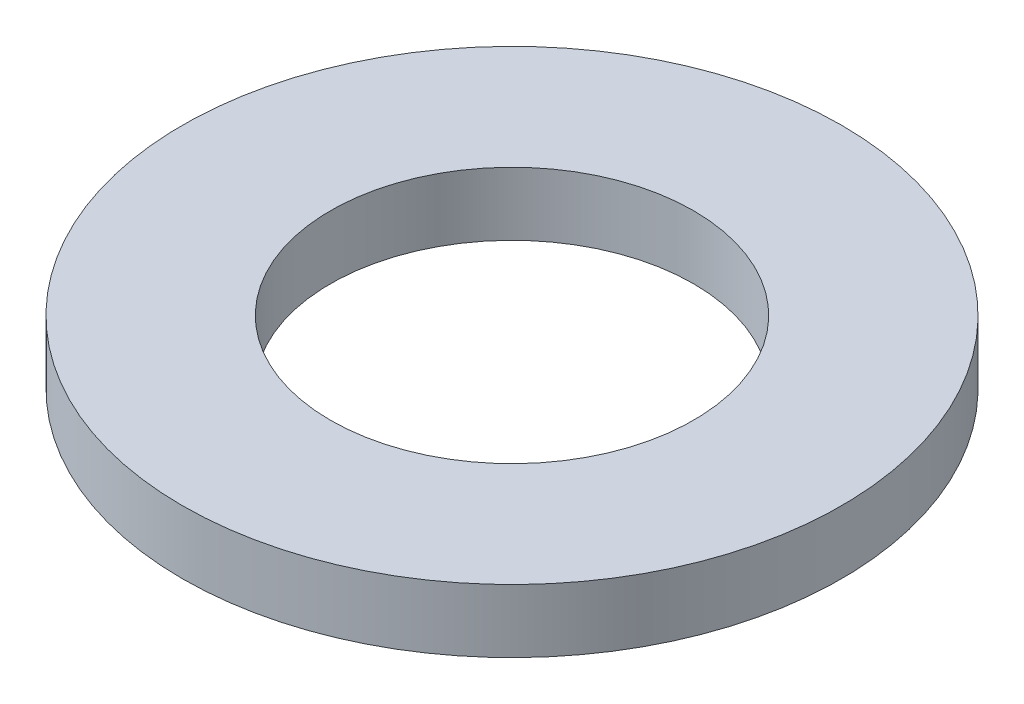
from build123d import *

# Parameters (mm, degrees)
SKETCH1_R           = 4.4958
BOSS_EXTRUDE1_DEPTH = 0.8636
SKETCH5_R           = 2.4765
CUT_EXTRUDE1_DEPTH  = 1.8636


with BuildPart() as part:
    # Sketch1 → Boss-Extrude1 (new body)
    with BuildSketch(Plane(origin=(0, 0, 0), x_dir=(1, 0, 0), z_dir=(0, 1, 0))):
        Circle(SKETCH1_R)
    extrude(amount=BOSS_EXTRUDE1_DEPTH)

    # Sketch5 → Cut-Extrude1 (cut, through all)
    with BuildSketch(Plane(origin=(0, 0.8636, 0), x_dir=(-1, 0, 0), z_dir=(0, 1, 0))):
        Circle(SKETCH5_R)
    extrude(amount=-CUT_EXTRUDE1_DEPTH, mode=Mode.SUBTRACT)


solid = part.part
